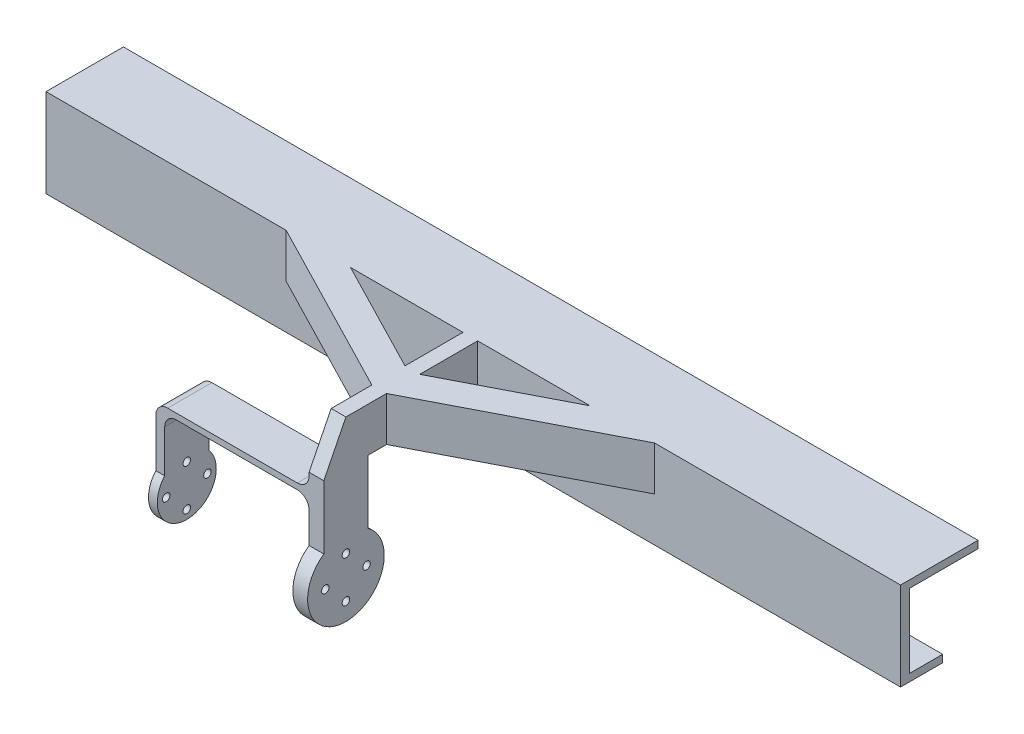
from build123d import *

# Parameters (mm, degrees)
SKETCH2_W                = 290
SKETCH2_H                = 30
SKETCH2_W_2              = 280
SKETCH2_H_2              = 25
BOSS_EXTRUDE1_DEPTH      = 23.28
SKETCH3_W                = 290
SKETCH3_H                = 30
BOSS_EXTRUDE2_DEPTH      = 3
SKETCH4_W                = 23.28
SKETCH4_H                = 25
CUT_EXTRUDE1_DEPTH       = 1
CUT_EXTRUDE1_DEPTH_BACK  = 291
BOSS_EXTRUDE3_DEPTH      = 2
BOSS_EXTRUDE3_DEPTH_BACK = 3
SKETCH6_R                = 10
CUT_EXTRUDE2_DEPTH       = 2
SKETCH7_R                = 1.275
CUT_EXTRUDE3_DEPTH       = 10
SKETCH8_W                = 290
SKETCH8_H                = 2.5
CUT_EXTRUDE4_DEPTH       = 12
BOSS_EXTRUDE4_DEPTH      = 15
ESQUISSE1_W              = 15
ESQUISSE1_H              = 2
BOSS_EXTRU_1_DEPTH       = 49
ESQUISSE2_R              = 1.275
BOSS_EXTRU_2_DEPTH       = 3
CONG_1_R                 = 4


with BuildPart() as part:
    # Sketch2 → Boss-Extrude1 (new body)
    with BuildSketch(Plane.XY.offset(1.715456747)):
        Rectangle(SKETCH2_W, SKETCH2_H)
        Rectangle(SKETCH2_W_2, SKETCH2_H_2, mode=Mode.SUBTRACT)
    extrude(amount=BOSS_EXTRUDE1_DEPTH)

    # Sketch3 → Boss-Extrude2 (add)
    with BuildSketch(Plane.XY.offset(24.995456747)):
        Rectangle(SKETCH3_W, SKETCH3_H)
    extrude(amount=BOSS_EXTRUDE2_DEPTH)

    # Sketch4 → Cut-Extrude1 (cut, two sides)
    with BuildSketch(Plane(origin=(145, 0, 0), x_dir=(0, 0, -1), z_dir=(1, 0, 0))) as cut_extrude1_sk:
        with Locations((-13.355456747, 0)):
            Rectangle(SKETCH4_W, SKETCH4_H)
    extrude(amount=CUT_EXTRUDE1_DEPTH, mode=Mode.SUBTRACT)
    extrude(cut_extrude1_sk.sketch, amount=-CUT_EXTRUDE1_DEPTH_BACK, mode=Mode.SUBTRACT)

    # Sketch5 → Boss-Extrude3 (add, two sides)
    with BuildSketch(Plane(origin=(-0.5, 0, 0), x_dir=(0, 0, -1), z_dir=(1, 0, 0))) as boss_extrude3_sk:
        with BuildLine():
            Line((-27.995456747, 0), (-27.995456747, 15))
            Line((-27.995456747, 15), (-72.715456747, 15))
            Line((-72.715456747, 15), (-80.215456747, 0))
            Line((-80.215456747, 0), (-80.215456747, -21.531619709))
            ThreePointArc((-80.215456747, -21.531619709), (-72.715456747, -45.15), (-65.215456747, -21.531619709))
            Line((-65.215456747, -21.531619709), (-65.215456747, 0))
            Line((-65.215456747, 0), (-27.995456747, 0))
        make_face()
    extrude(amount=BOSS_EXTRUDE3_DEPTH)
    extrude(boss_extrude3_sk.sketch, amount=-BOSS_EXTRUDE3_DEPTH_BACK)

    # Sketch6 → Cut-Extrude2 (cut)
    with BuildSketch(Plane(origin=(-3.5, 0, 0), x_dir=(0, 0, -1), z_dir=(1, 0, 0))):
        with Locations((-72.715456747, -32.15)):
            Circle(SKETCH6_R)
    extrude(amount=CUT_EXTRUDE2_DEPTH, mode=Mode.SUBTRACT)

    # Sketch7 → Cut-Extrude3 (cut)
    with BuildSketch(Plane.ZY.offset(3.5)):
        with Locations((72.715456747, -25.15)):
            Circle(SKETCH7_R)
        with Locations((79.715456747, -32.15)):
            Circle(SKETCH7_R)
        with Locations((72.715456747, -39.15)):
            Circle(SKETCH7_R)
        with Locations((65.715456747, -32.15)):
            Circle(SKETCH7_R)
    extrude(amount=-CUT_EXTRUDE3_DEPTH, mode=Mode.SUBTRACT)

    # Sketch8 → Cut-Extrude4 (cut)
    with BuildSketch(Plane(origin=(0, 0, 1.715456747), x_dir=(-1, 0, 0), z_dir=(0, 0, -1))):
        with Locations((0, -13.75)):
            Rectangle(SKETCH8_W, SKETCH8_H)
    extrude(amount=-CUT_EXTRUDE4_DEPTH, mode=Mode.SUBTRACT)

    # Sketch9 → Boss-Extrude4 (add)
    with BuildSketch(Plane(origin=(0, 15, 0), x_dir=(1, 0, 0), z_dir=(0, 1, 0))):
        Polygon((-3.5, -58.92224084), (-63.5, -27.995456747), (-41.673741056, -27.995456747), (-3.5, -47.671974209), align=None)
        Polygon((61.5, -27.995456747), (39.673741056, -27.995456747), (1.5, -47.671974209), (1.5, -58.92224084), align=None)
    extrude(amount=-BOSS_EXTRUDE4_DEPTH)

    # Esquisse1 → Boss.-Extru.1 (add)
    with BuildSketch(Plane.ZY.offset(3.5)):
        with Locations((72.715456747, -6.15)):
            Rectangle(ESQUISSE1_W, ESQUISSE1_H)
    extrude(amount=BOSS_EXTRU_1_DEPTH)

    # Esquisse2 → Boss.-Extru.2 (add)
    with BuildSketch(Plane.ZY.offset(52.5)):
        with BuildLine():
            Line((65.215456747, -21.531619709), (65.215456747, -25.535621722))
            ThreePointArc((65.215456747, -25.535621722), (72.715456747, -42.15), (80.215456747, -25.535621722))
            Line((80.215456747, -25.535621722), (80.215456747, -21.531619709))
            Line((80.215456747, -21.531619709), (80.215456747, -7.15))
            Line((80.215456747, -7.15), (80.215456747, -5.15))
            Line((80.215456747, -5.15), (65.215456747, -5.15))
            Line((65.215456747, -5.15), (65.215456747, -7.15))
            Line((65.215456747, -7.15), (65.215456747, -12.828367585))
            Line((65.215456747, -12.828367585), (65.215456747, -21.531619709))
        make_face()
        with Locations((72.715456747, -39.15)):
            Circle(ESQUISSE2_R, mode=Mode.SUBTRACT)
        with Locations((79.715456747, -32.15)):
            Circle(ESQUISSE2_R, mode=Mode.SUBTRACT)
        with Locations((72.715456747, -25.15)):
            Circle(ESQUISSE2_R, mode=Mode.SUBTRACT)
        with Locations((65.715456747, -32.15)):
            Circle(ESQUISSE2_R, mode=Mode.SUBTRACT)
    extrude(amount=BOSS_EXTRU_2_DEPTH)

    # Congé1
    cong_1_edges = [part.edges().sort_by_distance(p)[0] for p in [
        (-3.5, -7.15, 72.715456747),
        (-3.5, -5.15, 72.715456747),
        (-52.5, -7.15, 72.715456747),
        (-55.5, -5.15, 72.715456747),
    ]]
    fillet(cong_1_edges, radius=CONG_1_R)


solid = part.part
